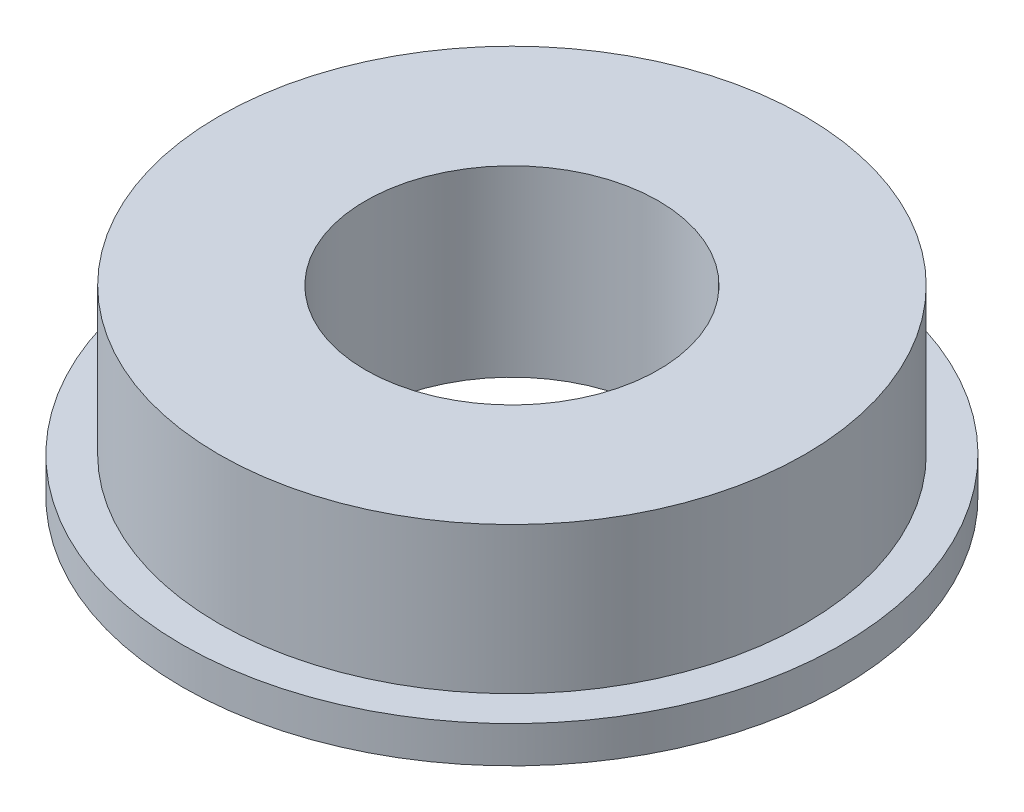
from build123d import *

# Parameters (mm, degrees)
SKETCH_1_R          = 9
SKETCH_1_R_2        = 4
EXTRUDE_1_DEPTH     = 5
SKETCH_2_R          = 9
SKETCH_2_R_2        = 8
CUT_EXTRUDE_1_DEPTH = 4


with BuildPart() as part:
    # 草图1 → 凸台-拉伸1 (new body)
    with BuildSketch(Plane(origin=(0, 0, 0), x_dir=(1, 0, 0), z_dir=(0, 1, 0))):
        Circle(SKETCH_1_R)
        Circle(SKETCH_1_R_2, mode=Mode.SUBTRACT)
    extrude(amount=EXTRUDE_1_DEPTH)

    # 草图2 → 切除-拉伸1 (cut)
    with BuildSketch(Plane(origin=(0, 5, 0), x_dir=(1, 0, 0), z_dir=(0, 1, 0))):
        Circle(SKETCH_2_R)
        Circle(SKETCH_2_R_2, mode=Mode.SUBTRACT)
    extrude(amount=-CUT_EXTRUDE_1_DEPTH, mode=Mode.SUBTRACT)


solid = part.part
